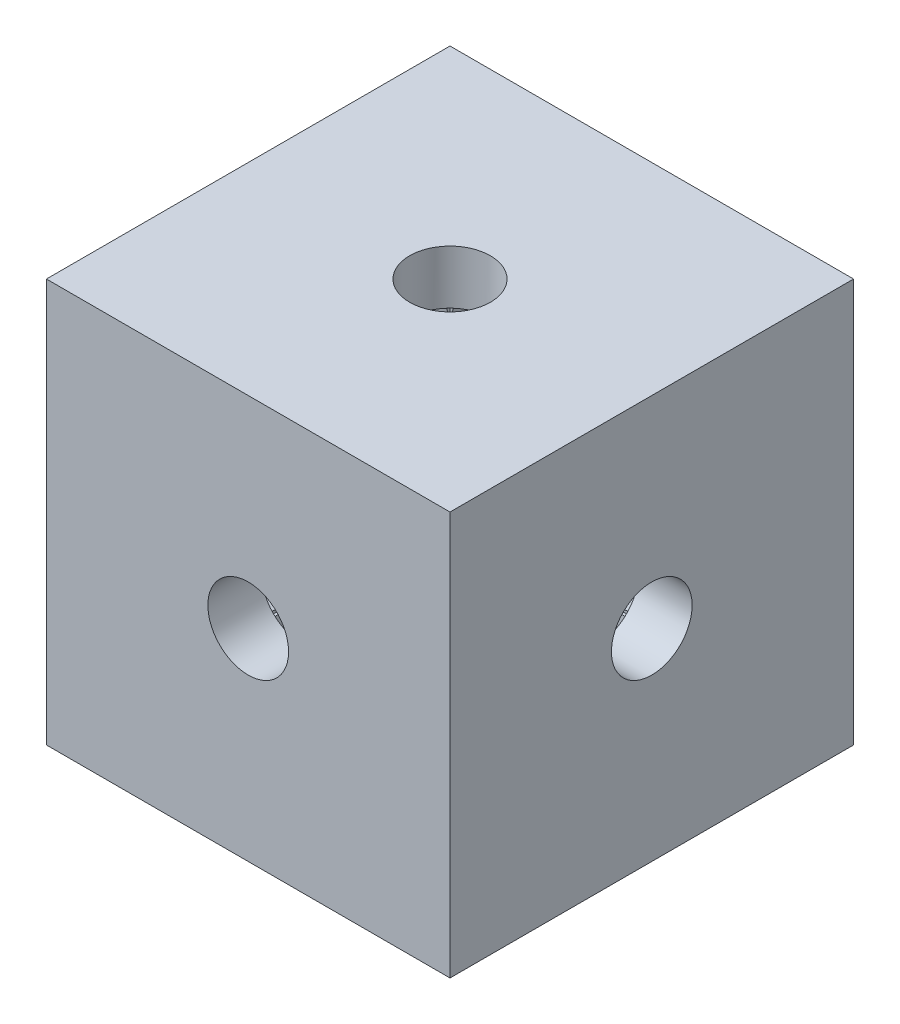
from build123d import *

# Parameters (mm, degrees)
SKETCH1_W           = 15
SKETCH1_H           = 15
SKETCH1_W_2         = 11
SKETCH1_H_2         = 11
BOSS_EXTRUDE1_DEPTH = 2
SKETCH5_W           = 2
SKETCH5_H           = 2
BOSS_EXTRUDE2_DEPTH = 11
SKETCH8_W           = 15
SKETCH8_H           = 15
SKETCH8_W_2         = 11
SKETCH8_H_2         = 11
BOSS_EXTRUDE3_DEPTH = 2
BOSS_EXTRUDE4_DEPTH = 2
BOSS_EXTRUDE5_DEPTH = 2
BOSS_EXTRUDE6_DEPTH = 2
SKETCH12_W          = 11
SKETCH12_H          = 11
SKETCH12_R          = 1.5
BOSS_EXTRUDE7_DEPTH = 2
SKETCH13_W          = 11
SKETCH13_H          = 11
SKETCH13_R          = 1.5
BOSS_EXTRUDE8_DEPTH = 2
BOSS_EXTRUDE9_START = -2
SKETCH14_W          = 11
SKETCH14_H          = 11
SKETCH14_R          = 1.5
BOSS_EXTRUDE9_DEPTH = 2


with BuildPart() as part:
    # Sketch1 → Boss-Extrude1 (new body)
    with BuildSketch(Plane(origin=(0, 0, 0), x_dir=(1, 0, 0), z_dir=(0, 1, 0))):
        Rectangle(SKETCH1_W, SKETCH1_H)
        Rectangle(SKETCH1_W_2, SKETCH1_H_2, mode=Mode.SUBTRACT)
    extrude(amount=BOSS_EXTRUDE1_DEPTH)

    # Sketch5 → Boss-Extrude2 (add)
    with BuildSketch(Plane(origin=(0, 2, 0), x_dir=(1, 0, 0), z_dir=(0, 1, 0))):
        with Locations((-6.5, -6.5)):
            Rectangle(SKETCH5_W, SKETCH5_H)
        with Locations((6.5, -6.5)):
            Rectangle(SKETCH5_W, SKETCH5_H)
        with Locations((6.5, 6.5)):
            Rectangle(SKETCH5_W, SKETCH5_H)
        with Locations((-6.5, 6.5)):
            Rectangle(SKETCH5_W, SKETCH5_H)
    extrude(amount=BOSS_EXTRUDE2_DEPTH)

    # Sketch8 → Boss-Extrude3 (add)
    with BuildSketch(Plane(origin=(0, 13, 0), x_dir=(1, 0, 0), z_dir=(0, 1, 0))):
        Rectangle(SKETCH8_W, SKETCH8_H)
        Rectangle(SKETCH8_W_2, SKETCH8_H_2, mode=Mode.SUBTRACT)
    extrude(amount=BOSS_EXTRUDE3_DEPTH)

    # Sketch9 → Boss-Extrude4 (add)
    with BuildSketch(Plane.XZ):
        with BuildLine():
            Line((5.5, 0), (5.5, 5.5))
            Line((5.5, 5.5), (-2e-08, 5.5))
            ThreePointArc((-2e-08, 5.5), (3.88908729, 3.889087304), (5.5, 0))
        make_face()
        with BuildLine():
            ThreePointArc((-5.5, 1.5e-08), (-3.889087298, 3.889087295), (-2e-08, 5.5))
            Line((-2e-08, 5.5), (-5.5, 5.5))
            Line((-5.5, 5.5), (-5.5, 1.5e-08))
        make_face()
        with BuildLine():
            Line((5.5, -5.5), (5.5, 0))
            ThreePointArc((5.5, 0), (3.889087294, -3.889087299), (-7e-09, -5.5))
            Line((-7e-09, -5.5), (5.5, -5.5))
        make_face()
        with BuildLine():
            ThreePointArc((-7e-09, -5.5), (-3.889087305, -3.889087288), (-5.5, 1.5e-08))
            Line((-5.5, 1.5e-08), (-5.5, -5.5))
            Line((-5.5, -5.5), (-7e-09, -5.5))
        make_face()
    extrude(amount=-BOSS_EXTRUDE4_DEPTH)

    # Sketch10 → Boss-Extrude5 (add)
    with BuildSketch(Plane(origin=(0, 0, -7.5), x_dir=(-1, 0, 0), z_dir=(0, 0, -1))):
        with BuildLine():
            Line((-5.5, 13), (-5.5, 7.500000001))
            ThreePointArc((-5.5, 7.500000001), (-3.889087296, 11.389087297), (0, 13))
            Line((0, 13), (-5.5, 13))
        make_face()
        with BuildLine():
            ThreePointArc((0, 13), (3.889087297, 11.389087297), (5.5, 7.5))
            Line((5.5, 7.5), (5.5, 13))
            Line((5.5, 13), (0, 13))
        make_face()
        with BuildLine():
            ThreePointArc((5.5, 7.5), (3.889087297, 3.610912703), (0, 2))
            Line((0, 2), (5.5, 2))
            Line((5.5, 2), (5.5, 7.5))
        make_face()
        with BuildLine():
            Line((-5.5, 7.500000001), (-5.5, 2))
            Line((-5.5, 2), (0, 2))
            ThreePointArc((0, 2), (-3.889087297, 3.610912704), (-5.5, 7.500000001))
        make_face()
    extrude(amount=-BOSS_EXTRUDE5_DEPTH)

    # Sketch11 → Boss-Extrude6 (add)
    with BuildSketch(Plane.ZY.offset(7.5)):
        with BuildLine():
            Line((-5.5, 13), (-5.5, 7.5))
            ThreePointArc((-5.5, 7.5), (-3.88908729, 11.389087303), (1.9e-08, 13))
            Line((1.9e-08, 13), (-5.5, 13))
        make_face()
        with BuildLine():
            ThreePointArc((1.9e-08, 13), (3.889087303, 11.38908729), (5.5, 7.5))
            Line((5.5, 7.5), (5.5, 13))
            Line((5.5, 13), (1.9e-08, 13))
        make_face()
        with BuildLine():
            Line((-5.5, 7.5), (-5.5, 2))
            Line((-5.5, 2), (-7e-09, 2))
            ThreePointArc((-7e-09, 2), (-3.889087299, 3.610912706), (-5.5, 7.5))
        make_face()
        with BuildLine():
            ThreePointArc((5.5, 7.5), (3.889087294, 3.610912701), (-7e-09, 2))
            Line((-7e-09, 2), (5.5, 2))
            Line((5.5, 2), (5.5, 7.5))
        make_face()
    extrude(amount=-BOSS_EXTRUDE6_DEPTH)

    # Sketch12 → Boss-Extrude7 (add)
    with BuildSketch(Plane.XY.offset(7.5)):
        with Locations((0, 7.5)):
            Rectangle(SKETCH12_W, SKETCH12_H)
        with Locations((0, 7.5)):
            Circle(SKETCH12_R, mode=Mode.SUBTRACT)
    extrude(amount=-BOSS_EXTRUDE7_DEPTH)

    # Sketch13 → Boss-Extrude8 (add)
    with BuildSketch(Plane(origin=(0, 15, 0), x_dir=(1, 0, 0), z_dir=(0, 1, 0))):
        Rectangle(SKETCH13_W, SKETCH13_H)
        Circle(SKETCH13_R, mode=Mode.SUBTRACT)
    extrude(amount=-BOSS_EXTRUDE8_DEPTH)

    # Sketch14 → Boss-Extrude9 (add)
    with BuildSketch(Plane(origin=(7.5, 0, 0), x_dir=(0, 0, -1), z_dir=(1, 0, 0)).offset(BOSS_EXTRUDE9_START)):
        with Locations((0, 7.5)):
            Rectangle(SKETCH14_W, SKETCH14_H)
        with Locations((0, 7.5)):
            Circle(SKETCH14_R, mode=Mode.SUBTRACT)
    extrude(amount=BOSS_EXTRUDE9_DEPTH)


solid = part.part
